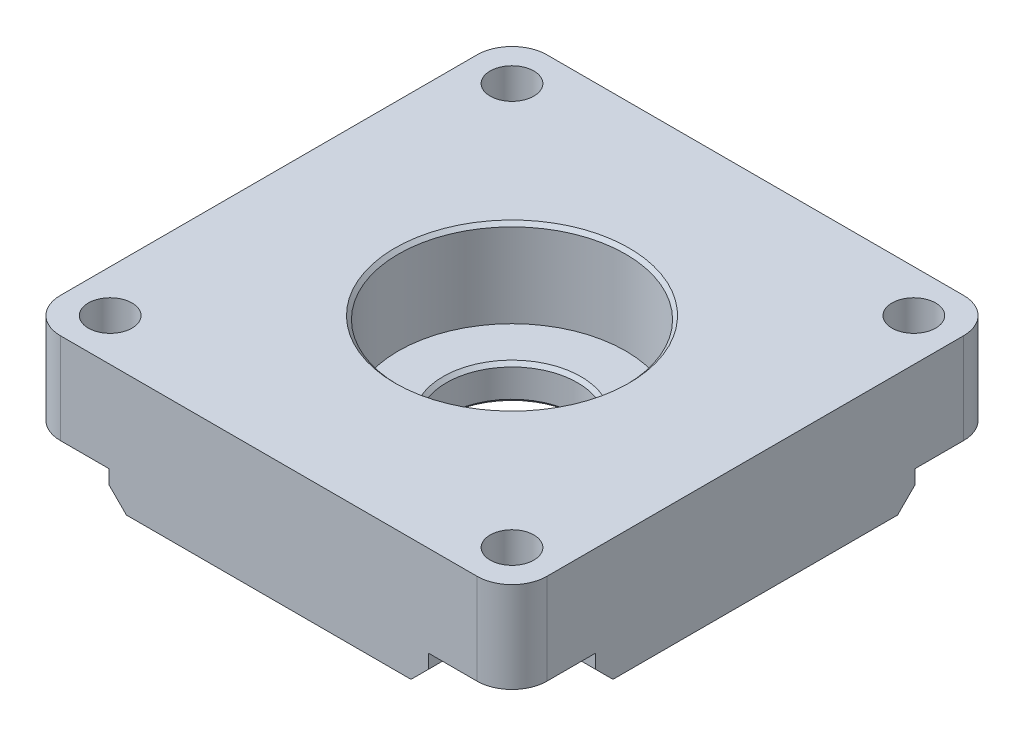
from build123d import *

# Parameters (mm, degrees)
SKETCH_1_W          = 27.85
SKETCH_1_H          = 27.85
SKETCH_1_R          = 1.25
SKETCH_1_R_2        = 3.75
EXTRUDE_1_DEPTH     = 7
SKETCH_1_4_R        = 1.25
CUT_EXTRUDE_1_DEPTH = 1.8
CHAMFER_1_SIZE      = 1
FILLET_1_R          = 2
SKETCH_3_R          = 6.5
CUT_EXTRUDE_2_DEPTH = 5
CHAMFER_2_SIZE      = 0.2


with BuildPart() as part:
    # Эскиз1 → Бобышка-Вытянуть1 (new body)
    with BuildSketch(Plane(origin=(0, 0, 0), x_dir=(1, 0, 0), z_dir=(0, 1, 0))):
        Rectangle(SKETCH_1_W, SKETCH_1_H)
        with Locations((-11.5, 11.5)):
            Circle(SKETCH_1_R, mode=Mode.SUBTRACT)
        Circle(SKETCH_1_R_2, mode=Mode.SUBTRACT)
        with Locations((11.5, 11.5)):
            Circle(SKETCH_1_R, mode=Mode.SUBTRACT)
        with Locations((11.5, -11.5)):
            Circle(SKETCH_1_R, mode=Mode.SUBTRACT)
        with Locations((-11.5, -11.5)):
            Circle(SKETCH_1_R, mode=Mode.SUBTRACT)
    extrude(amount=EXTRUDE_1_DEPTH)

    # Эскиз1<4> → Вырез-Вытянуть1 (cut)
    # profile 1 of 4: a face of its own
    with BuildSketch(Plane(origin=(0, 0, 0), x_dir=(1, 0, 0), z_dir=(0, 1, 0))):
        with BuildLine():
            Line((-9.144874717, 13.925), (-13.925, 13.925))
            Line((-13.925, 13.925), (-13.925, 9.144874717))
            Line((-13.925, 9.144874717), (-11.144874717, 9.144874717))
            ThreePointArc((-11.144874717, 9.144874717), (-9.730661155, 9.730661155), (-9.144874717, 11.144874717))
            Line((-9.144874717, 11.144874717), (-9.144874717, 13.925))
        make_face()
        with Locations((-11.5, 11.5)):
            Circle(SKETCH_1_4_R, mode=Mode.SUBTRACT)
    # profile 2 of 4: a face of its own
    with BuildSketch(Plane(origin=(0, 0, 0), x_dir=(1, 0, 0), z_dir=(0, 1, 0))):
        with BuildLine():
            Line((13.925, 13.925), (9.144874717, 13.925))
            Line((9.144874717, 13.925), (9.144874717, 11.144874717))
            ThreePointArc((9.144874717, 11.144874717), (9.730661155, 9.730661155), (11.144874717, 9.144874717))
            Line((11.144874717, 9.144874717), (13.925, 9.144874717))
            Line((13.925, 9.144874717), (13.925, 13.925))
        make_face()
        with Locations((11.5, 11.5)):
            Circle(SKETCH_1_4_R, mode=Mode.SUBTRACT)
    # profile 3 of 4: a face of its own
    with BuildSketch(Plane(origin=(0, 0, 0), x_dir=(1, 0, 0), z_dir=(0, 1, 0))):
        with BuildLine():
            Line((-11.144874717, -9.144874717), (-13.925, -9.144874717))
            Line((-13.925, -9.144874717), (-13.925, -13.925))
            Line((-13.925, -13.925), (-9.144874717, -13.925))
            Line((-9.144874717, -13.925), (-9.144874717, -11.144874717))
            ThreePointArc((-9.144874717, -11.144874717), (-9.730661155, -9.730661155), (-11.144874717, -9.144874717))
        make_face()
        with Locations((-11.5, -11.5)):
            Circle(SKETCH_1_4_R, mode=Mode.SUBTRACT)
    # profile 4 of 4: a face of its own
    with BuildSketch(Plane(origin=(0, 0, 0), x_dir=(1, 0, 0), z_dir=(0, 1, 0))):
        with BuildLine():
            Line((13.925, -13.925), (13.925, -9.144874717))
            Line((13.925, -9.144874717), (11.144874717, -9.144874717))
            ThreePointArc((11.144874717, -9.144874717), (9.730661155, -9.730661155), (9.144874717, -11.144874717))
            Line((9.144874717, -11.144874717), (9.144874717, -13.925))
            Line((9.144874717, -13.925), (13.925, -13.925))
        make_face()
        with Locations((11.5, -11.5)):
            Circle(SKETCH_1_4_R, mode=Mode.SUBTRACT)
    extrude(amount=CUT_EXTRUDE_1_DEPTH, mode=Mode.SUBTRACT)

    # Фаска1
    chamfer_1_edges = [part.edges().sort_by_distance(p)[0] for p in [
        (9.144874717, 0, 12.534937359),
        (9.730661155, 0, 9.730661155),
        (12.534937359, 0, 9.144874717),
        (12.534937359, 0, -9.144874717),
        (9.730661155, 0, -9.730661155),
        (9.144874717, 0, -12.534937359),
        (-12.534937359, 0, 9.144874717),
        (-9.144874717, 0, 12.534937359),
        (-9.730661155, 0, 9.730661155),
        (-9.144874717, 0, -12.534937359),
        (-12.534937359, 0, -9.144874717),
        (-9.730661155, 0, -9.730661155),
    ]]
    chamfer(chamfer_1_edges, length=CHAMFER_1_SIZE)

    # Скругление1
    fillet_1_edges = [part.edges().sort_by_distance(p)[0] for p in [
        (-13.925, 4.4, -13.925),
        (-13.925, 4.4, 13.925),
        (13.925, 4.4, 13.925),
        (13.925, 4.4, -13.925),
    ]]
    fillet(fillet_1_edges, radius=FILLET_1_R)

    # Эскиз3 → Вырез-Вытянуть2 (cut)
    with BuildSketch(Plane(origin=(0, 7, 0), x_dir=(1, 0, 0), z_dir=(0, 1, 0))):
        Circle(SKETCH_3_R)
    extrude(amount=-CUT_EXTRUDE_2_DEPTH, mode=Mode.SUBTRACT)

    # Фаска2
    chamfer_2_edges = [part.edges().sort_by_distance(p)[0] for p in [
        (-3.75, 2, 0),
        (-6.5, 7, 0),
        (-3.75, 0, 0),
    ]]
    chamfer(chamfer_2_edges, length=CHAMFER_2_SIZE)


solid = part.part
